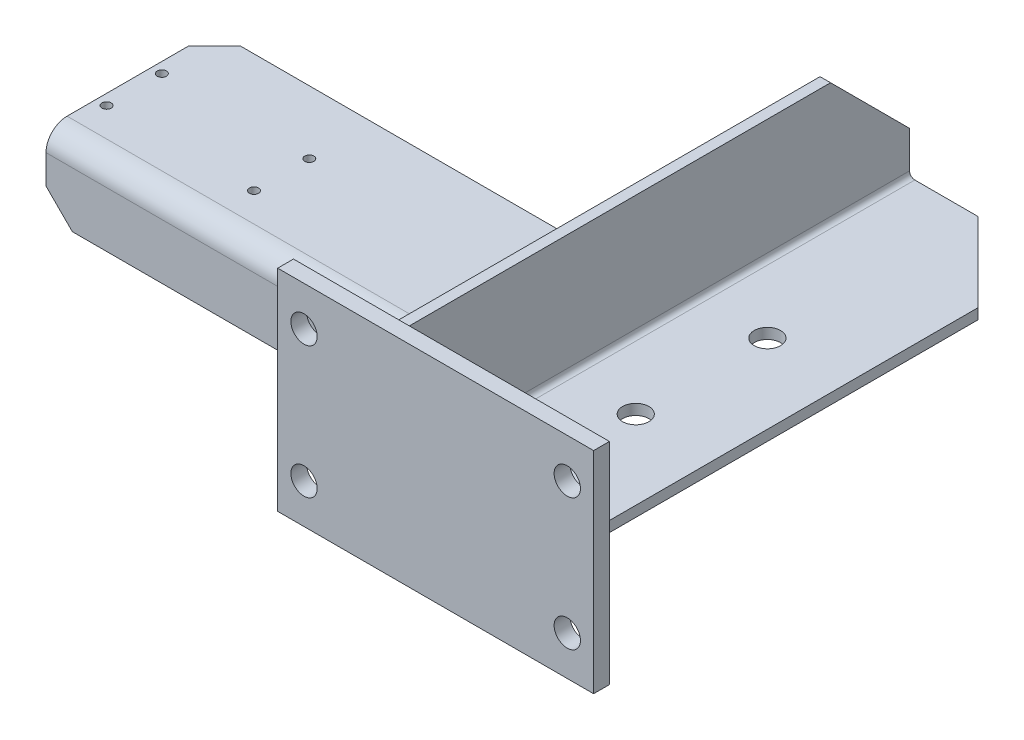
from build123d import *

# Parameters (mm, degrees)
EXTRUDE_1_DEPTH     = 200
SKETCH_2_W          = 120
SKETCH_2_H          = 80
SKETCH_2_R          = 5
EXTRUDE_2_DEPTH     = 6
CHAMFER_1_SIZE      = 30
SKETCH_3_R          = 5
CUT_EXTRUDE_1_DEPTH = 4
EXTRUDE_3_DEPTH     = 145
CHAMFER_2_SIZE      = 10
SKETCH_7_R          = 1.75
CUT_EXTRUDE_2_DEPTH = 4


with BuildPart() as part:
    # 草图1 → 凸台-拉伸1 (new body)
    with BuildSketch(Plane.XY):
        with BuildLine():
            Line((0, 6), (0, 50))
            Line((0, 50), (4, 50))
            Line((4, 50), (4, 6))
            ThreePointArc((4, 6), (4.585786438, 4.585786438), (6, 4))
            Line((6, 4), (60, 4))
            Line((60, 4), (60, 0))
            Line((60, 0), (6, 0))
            ThreePointArc((6, 0), (1.757359313, 1.757359313), (0, 6))
        make_face()
    extrude(amount=EXTRUDE_1_DEPTH)

    # 倒角1
    chamfer_1_edges = [part.edges().sort_by_distance(p)[0] for p in [
        (2, 50, 0),
        (60, 2, 0),
    ]]
    chamfer(chamfer_1_edges, length=CHAMFER_1_SIZE)

    # 草图3 → 切除-拉伸1 (cut)
    with BuildSketch(Plane(origin=(0, 4, 0), x_dir=(1, 0, 0), z_dir=(0, 1, 0))):
        with Locations((30, -130)):
            Circle(SKETCH_3_R)
        with Locations((30, -80)):
            Circle(SKETCH_3_R)
    extrude(amount=-CUT_EXTRUDE_1_DEPTH, mode=Mode.SUBTRACT)

    # 草图4 → 凸台-拉伸3 (add)
    with BuildSketch(Plane.ZY):
        with BuildLine():
            Line((179, 6), (175, 6))
            Line((175, 6), (175, 27))
            ThreePointArc((175, 27), (173.828427125, 29.828427125), (171, 31))
            Line((171, 31), (115, 31))
            Line((115, 31), (115, 35))
            Line((115, 35), (171, 35))
            ThreePointArc((171, 35), (176.656854249, 32.656854249), (179, 27))
            Line((179, 27), (179, 6))
        make_face()
    extrude(amount=EXTRUDE_3_DEPTH)

    # 倒角2
    chamfer_2_edges = [part.edges().sort_by_distance(p)[0] for p in [
        (-145, 6, 177),
        (-145, 33, 115),
    ]]
    chamfer(chamfer_2_edges, length=CHAMFER_2_SIZE)

    # 草图7 → 切除-拉伸2 (cut)
    with BuildSketch(Plane.XZ.offset(-31)):
        with Locations((-141, 160)):
            Circle(SKETCH_7_R)
        with Locations((-141, 139)):
            Circle(SKETCH_7_R)
        with Locations((-85, 139)):
            Circle(SKETCH_7_R)
        with Locations((-85, 160)):
            Circle(SKETCH_7_R)
    extrude(amount=-CUT_EXTRUDE_2_DEPTH, mode=Mode.SUBTRACT)


with BuildPart() as body_2:
    # 草图2 → 凸台-拉伸2 (new body)
    with BuildSketch(Plane.XY.offset(200)):
        with Locations((30, 20)):
            Rectangle(SKETCH_2_W, SKETCH_2_H)
        with Locations((-20, 45)):
            Circle(SKETCH_2_R, mode=Mode.SUBTRACT)
        with Locations((80, 45)):
            Circle(SKETCH_2_R, mode=Mode.SUBTRACT)
        with Locations((-20, -5)):
            Circle(SKETCH_2_R, mode=Mode.SUBTRACT)
        with Locations((80, -5)):
            Circle(SKETCH_2_R, mode=Mode.SUBTRACT)
    extrude(amount=EXTRUDE_2_DEPTH)


solid = Compound([part.part, body_2.part])
